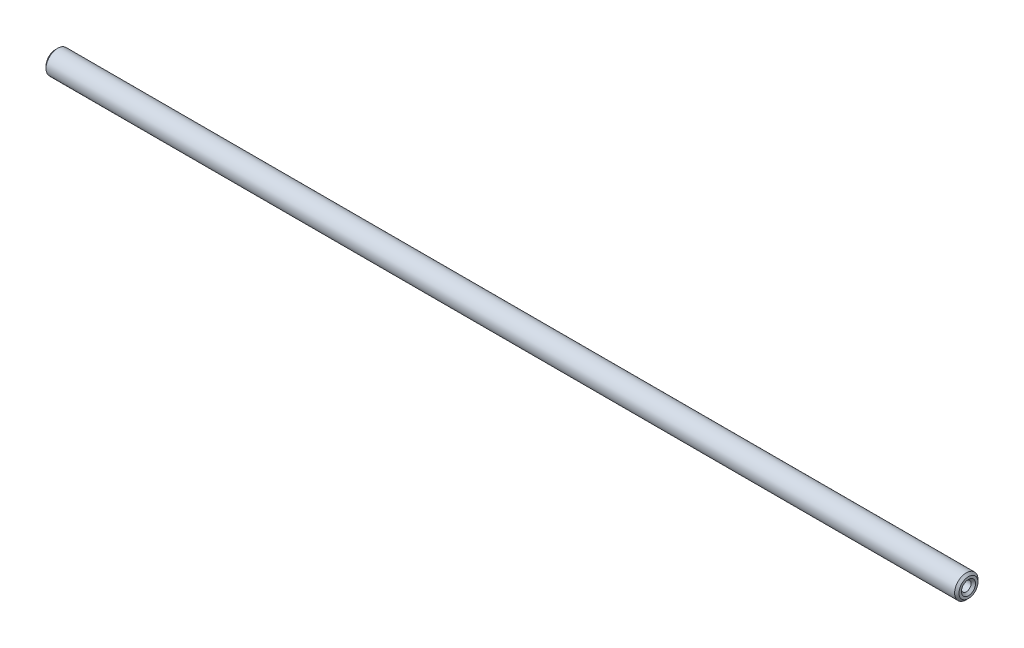
from build123d import *

# Parameters (mm, degrees)
ESQUISSE1_R             = 4
BOSS_EXTRU_1_DEPTH      = 156
ESQUISSE2_R             = 1.65
ENL_V_MAT_EXTRU_1_DEPTH = 313
CHANFREIN1_SIZE         = 0.75


with BuildPart() as part:
    # Esquisse1 → Boss.-Extru.1 (new body, symmetric)
    with BuildSketch(Plane(origin=(0, 0, 0), x_dir=(0, 0, -1), z_dir=(1, 0, 0))):
        Circle(ESQUISSE1_R)
    extrude(amount=BOSS_EXTRU_1_DEPTH, both=True)

    # Esquisse2 → Enlèv. mat.-Extru.1 (cut, through all)
    with BuildSketch(Plane.ZY.offset(156)):
        Circle(ESQUISSE2_R)
    extrude(amount=-ENL_V_MAT_EXTRU_1_DEPTH, mode=Mode.SUBTRACT)

    # Chanfrein1
    chanfrein1_edges = [part.edges().sort_by_distance(p)[0] for p in [
        (-156, 0, 4),
        (156, 0, 4),
        (156, 0, -1.65),
        (-156, 0, -1.65),
    ]]
    chamfer(chanfrein1_edges, length=CHANFREIN1_SIZE)


solid = part.part
